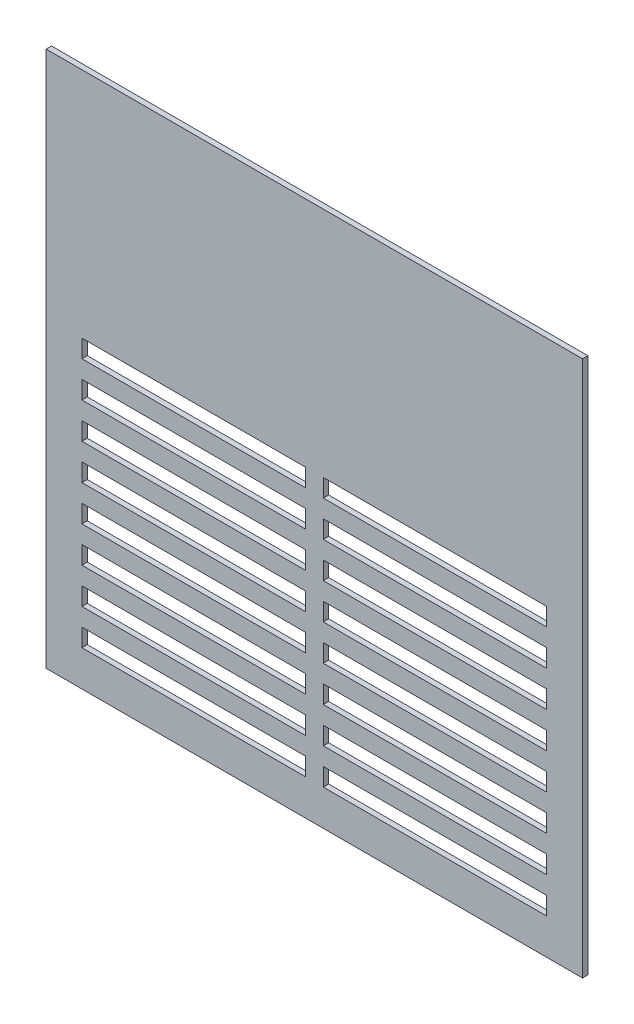
from build123d import *

# Parameters (mm, degrees)
CROQUIS1_W              = 300
CROQUIS1_H              = 300
SALIENTE_EXTRUIR1_DEPTH = 3
CROQUIS2_W              = 125
CROQUIS2_H              = 10
CORTAR_EXTRUIR1_DEPTH   = 10


with BuildPart() as part:
    # Croquis1 → Saliente-Extruir1 (new body)
    with BuildSketch(Plane.XY):
        with Locations((150, 150)):
            Rectangle(CROQUIS1_W, CROQUIS1_H)
    extrude(amount=SALIENTE_EXTRUIR1_DEPTH)

    # Croquis2 → Cortar-Extruir1 (cut)
    with BuildSketch(Plane.XY.offset(3)):
        with Locations((82.5, 25)):
            Rectangle(CROQUIS2_W, CROQUIS2_H)
        with Locations((82.5, 165)):
            Rectangle(CROQUIS2_W, CROQUIS2_H)
        with Locations((82.5, 145)):
            Rectangle(CROQUIS2_W, CROQUIS2_H)
        with Locations((82.5, 125)):
            Rectangle(CROQUIS2_W, CROQUIS2_H)
        with Locations((82.5, 105)):
            Rectangle(CROQUIS2_W, CROQUIS2_H)
        with Locations((82.5, 85)):
            Rectangle(CROQUIS2_W, CROQUIS2_H)
        with Locations((82.5, 65)):
            Rectangle(CROQUIS2_W, CROQUIS2_H)
        with Locations((82.5, 45)):
            Rectangle(CROQUIS2_W, CROQUIS2_H)
        with Locations((217.5, 25)):
            Rectangle(CROQUIS2_W, CROQUIS2_H)
        with Locations((217.5, 45)):
            Rectangle(CROQUIS2_W, CROQUIS2_H)
        with Locations((217.5, 65)):
            Rectangle(CROQUIS2_W, CROQUIS2_H)
        with Locations((217.5, 85)):
            Rectangle(CROQUIS2_W, CROQUIS2_H)
        with Locations((217.5, 105)):
            Rectangle(CROQUIS2_W, CROQUIS2_H)
        with Locations((217.5, 125)):
            Rectangle(CROQUIS2_W, CROQUIS2_H)
        with Locations((217.5, 145)):
            Rectangle(CROQUIS2_W, CROQUIS2_H)
        with Locations((217.5, 165)):
            Rectangle(CROQUIS2_W, CROQUIS2_H)
    extrude(amount=-CORTAR_EXTRUIR1_DEPTH, mode=Mode.SUBTRACT)


solid = part.part
